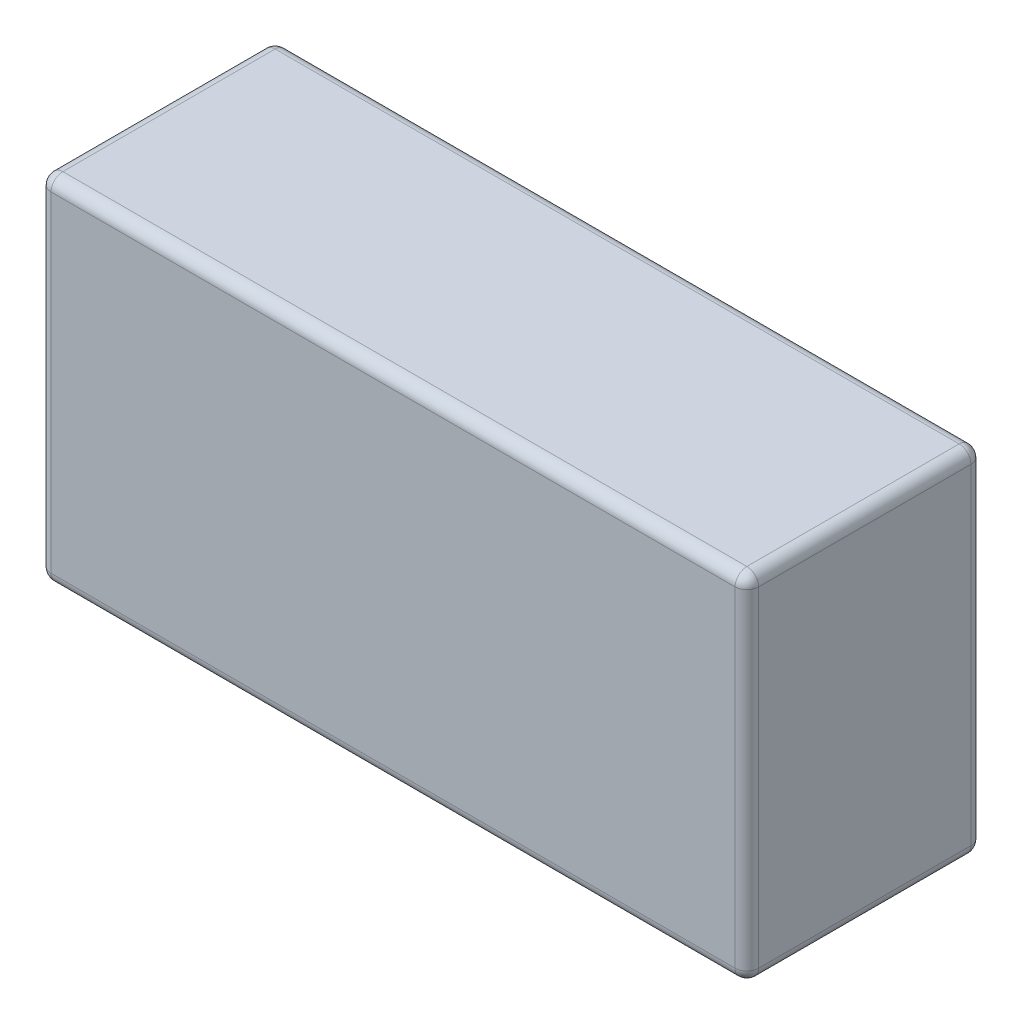
from build123d import *

# Parameters (mm, degrees)
CROQUIS1_W              = 60
CROQUIS1_H              = 30
SALIENTE_EXTRUIR1_DEPTH = 20
REDONDEO1_R             = 1


with BuildPart() as part:
    # Croquis1 → Saliente-Extruir1 (new body)
    with BuildSketch(Plane.XY):
        Rectangle(CROQUIS1_W, CROQUIS1_H)
    extrude(amount=SALIENTE_EXTRUIR1_DEPTH)

    # Redondeo1
    redondeo1_edges = [part.edges().sort_by_distance(p)[0] for p in [
        (-30, 0, 20),
        (0, -15, 20),
        (30, 0, 20),
        (0, -15, 0),
        (-30, 0, 0),
        (0, 15, 0),
        (30, 0, 0),
        (30, -15, 10),
        (-30, -15, 10),
        (-30, 15, 10),
        (30, 15, 10),
        (0, 15, 20),
    ]]
    fillet(redondeo1_edges, radius=REDONDEO1_R)


solid = part.part
